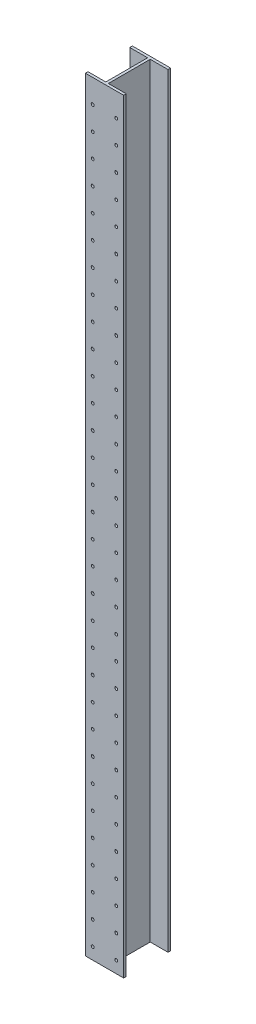
from build123d import *

# Parameters (mm, degrees)
BOSS_EXTRUDE1_DEPTH = 3302
SKETCH2_R           = 6.35
CUT_EXTRUDE1_DEPTH  = 11.176
LPATTERN1_COUNT     = 32
LPATTERN1_PITCH     = 101.6


with BuildPart() as part:
    # Sketch1 → Boss-Extrude1 (new body)
    with BuildSketch(Plane(origin=(0, 0, 0), x_dir=(1, 0, 0), z_dir=(0, 1, 0))):
        Polygon((-5.588, -90.424), (-5.588, 90.424), (-82.55, 90.424), (-82.55, 101.6), (82.55, 101.6), (82.55, 90.424), (5.588, 90.424), (5.588, -90.424), (82.55, -90.424), (82.55, -101.6), (-82.55, -101.6), (-82.55, -90.424), align=None)
    extrude(amount=BOSS_EXTRUDE1_DEPTH)

    # Sketch2 → Cut-Extrude1 (cut)
    with BuildSketch(Plane.XY.offset(101.6)):
        with Locations((-50.8, 50.8)):
            Circle(SKETCH2_R)
        with Locations((50.8, 50.8)):
            Circle(SKETCH2_R)
    cut_extrude1 = extrude(amount=-CUT_EXTRUDE1_DEPTH, mode=Mode.SUBTRACT)

    # LPattern1: Cut-Extrude1 ×32
    with Locations(*[(0, i * LPATTERN1_PITCH, 0) for i in range(1, LPATTERN1_COUNT)]):
        add(cut_extrude1, mode=Mode.SUBTRACT)


solid = part.part
